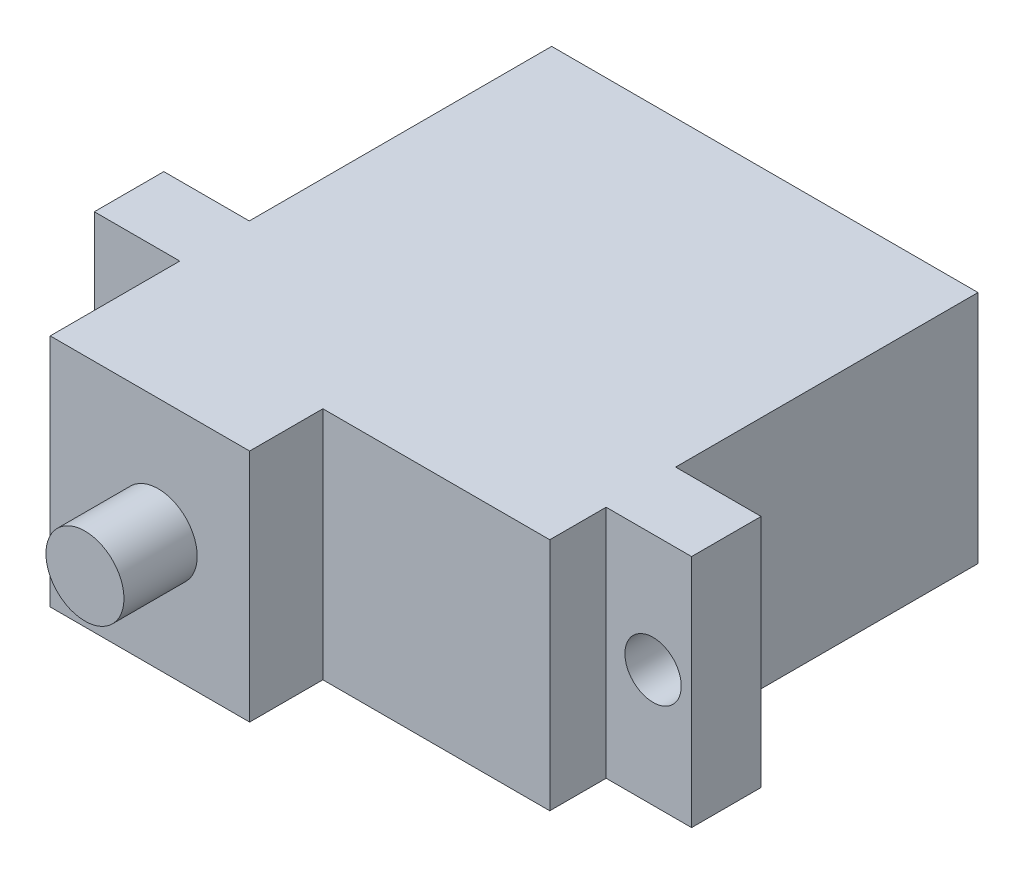
from build123d import *

# Parameters (mm, degrees)
SKETCH1_W           = 22.7
SKETCH1_H           = 12.5
BOSS_EXTRUDE1_DEPTH = 22.8
SKETCH2_W           = 4.55
SKETCH2_H           = 12.5
BOSS_EXTRUDE2_DEPTH = 6.7
SKETCH3_W           = 4.55
SKETCH3_H           = 3
CUT_EXTRUDE1_DEPTH  = 13.5
SKETCH4_R           = 1.5
CUT_EXTRUDE2_DEPTH  = 16.1
SKETCH6_W           = 10.618713929
SKETCH6_H           = 12.5
BOSS_EXTRUDE4_DEPTH = 3.9
SKETCH8_R           = 2.077581334
BOSS_EXTRUDE5_DEPTH = 3.9


with BuildPart() as part:
    # Sketch1 → Boss-Extrude1 (new body)
    with BuildSketch(Plane.XY):
        Rectangle(SKETCH1_W, SKETCH1_H)
    extrude(amount=BOSS_EXTRUDE1_DEPTH)

    # Sketch2 → Boss-Extrude2 (add)
    with BuildSketch(Plane.XY.offset(22.8)):
        with Locations((-13.625, 0)):
            Rectangle(SKETCH2_W, SKETCH2_H)
        with Locations((13.625, 0)):
            Rectangle(SKETCH2_W, SKETCH2_H)
    extrude(amount=-BOSS_EXTRUDE2_DEPTH)

    # Sketch3 → Cut-Extrude1 (cut, through all)
    with BuildSketch(Plane.XZ.offset(6.25)):
        with Locations((-13.625, 21.3)):
            Rectangle(SKETCH3_W, SKETCH3_H)
        with Locations((13.625, 21.3)):
            Rectangle(SKETCH3_W, SKETCH3_H)
    extrude(amount=-CUT_EXTRUDE1_DEPTH, mode=Mode.SUBTRACT)

    # Sketch4 → Cut-Extrude2 (cut)
    with BuildSketch(Plane.XY.offset(19.8)):
        with Locations((13.85, 0)):
            Circle(SKETCH4_R)
        with Locations((-13.85, 0)):
            Circle(SKETCH4_R)
    extrude(amount=-CUT_EXTRUDE2_DEPTH, mode=Mode.SUBTRACT)

    # Sketch6 → Boss-Extrude4 (add)
    with BuildSketch(Plane.XY.offset(22.8)):
        with Locations((-6.040643036, 0)):
            Rectangle(SKETCH6_W, SKETCH6_H)
    extrude(amount=BOSS_EXTRUDE4_DEPTH)

    # Sketch8 → Boss-Extrude5 (add)
    with BuildSketch(Plane.XY.offset(26.7)):
        with Locations((-5.6, 0)):
            Circle(SKETCH8_R)
    extrude(amount=BOSS_EXTRUDE5_DEPTH)


solid = part.part
